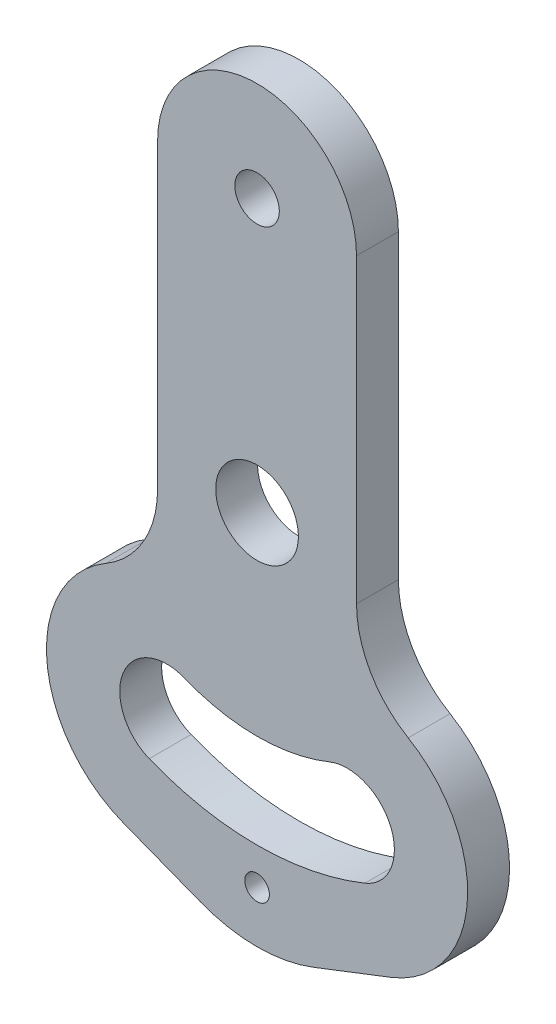
from build123d import *

# Parameters (mm, degrees)
SKETCH_1_R      = 7.9
SKETCH_1_R_2    = 4.25
SKETCH_1_R_3    = 2.35
EXTRUDE_1_DEPTH = 8
FILLET_1_R      = 30


with BuildPart() as part:
    # Эскиз1 → Бобышка-Вытянуть1 (new body)
    with BuildSketch(Plane.XY):
        with BuildLine():
            Line((-19, 114), (-19, 56.432557211))
            ThreePointArc((-19, 56.432557211), (-21.643532577, 46.495100866), (-28.875303859, 39.18464348))
            ThreePointArc((-28.875303859, 39.18464348), (-40.157482483, 17.500808258), (-25.546486414, -2.094983595))
            Line((-25.546486414, -2.094983595), (0, -12))
            Line((0, -12), (25.546486414, -2.094983595))
            ThreePointArc((25.546486414, -2.094983595), (40.157482483, 17.500808258), (28.875303859, 39.18464348))
            ThreePointArc((28.875303859, 39.18464348), (21.643532577, 46.495100866), (19, 56.432557211))
            Line((19, 56.432557211), (19, 114))
            ThreePointArc((19, 114), (0, 133), (-19, 114))
        make_face()
        with Locations((0, 62)):
            Circle(SKETCH_1_R, mode=Mode.SUBTRACT)
        with Locations((0, 114)):
            Circle(SKETCH_1_R_2, mode=Mode.SUBTRACT)
        Circle(SKETCH_1_R_3, mode=Mode.SUBTRACT)
        with BuildLine():
            ThreePointArc((-20.603362638, 11.004887999), (0, 7), (20.603362638, 11.004887999))
            ThreePointArc((20.603362638, 11.004887999), (25.576557988, 22.721002031), (13.860443956, 27.694197381))
            ThreePointArc((13.860443956, 27.694197381), (0, 25), (-13.860443956, 27.694197381))
            ThreePointArc((-13.860443956, 27.694197381), (-25.576557988, 22.721002031), (-20.603362638, 11.004887999))
        make_face(mode=Mode.SUBTRACT)
    extrude(amount=EXTRUDE_1_DEPTH)

    # Скругление1
    fillet_1_edges = [part.edges().sort_by_distance(p)[0] for p in [
        (0, -12, 4),
    ]]
    fillet(fillet_1_edges, radius=FILLET_1_R)


solid = part.part
